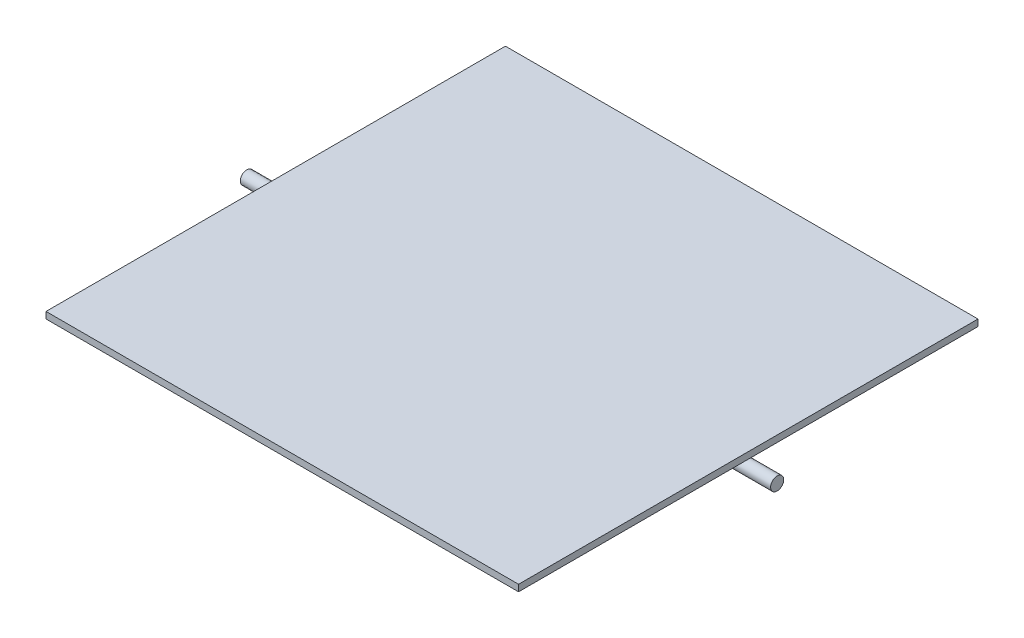
from build123d import *

# Parameters (mm, degrees)
ESQUISSE1_W        = 360
ESQUISSE1_H        = 350
BOSS_EXTRU_1_DEPTH = 5
ESQUISSE2_R        = 5
BOSS_EXTRU_2_DEPTH = 202


with BuildPart() as part:
    # Esquisse1 → Boss.-Extru.1 (new body)
    with BuildSketch(Plane(origin=(0, 0, 0), x_dir=(1, 0, 0), z_dir=(0, 1, 0))):
        Rectangle(ESQUISSE1_W, ESQUISSE1_H)
    extrude(amount=BOSS_EXTRU_1_DEPTH)


with BuildPart() as body_2:
    # Esquisse2 → Boss.-Extru.2 (new body, symmetric)
    with BuildSketch(Plane(origin=(0, 0, 0), x_dir=(0, 0, -1), z_dir=(1, 0, 0))):
        with Locations((0, -5)):
            Circle(ESQUISSE2_R)
    extrude(amount=BOSS_EXTRU_2_DEPTH, both=True)


solid = Compound([part.part, body_2.part])
